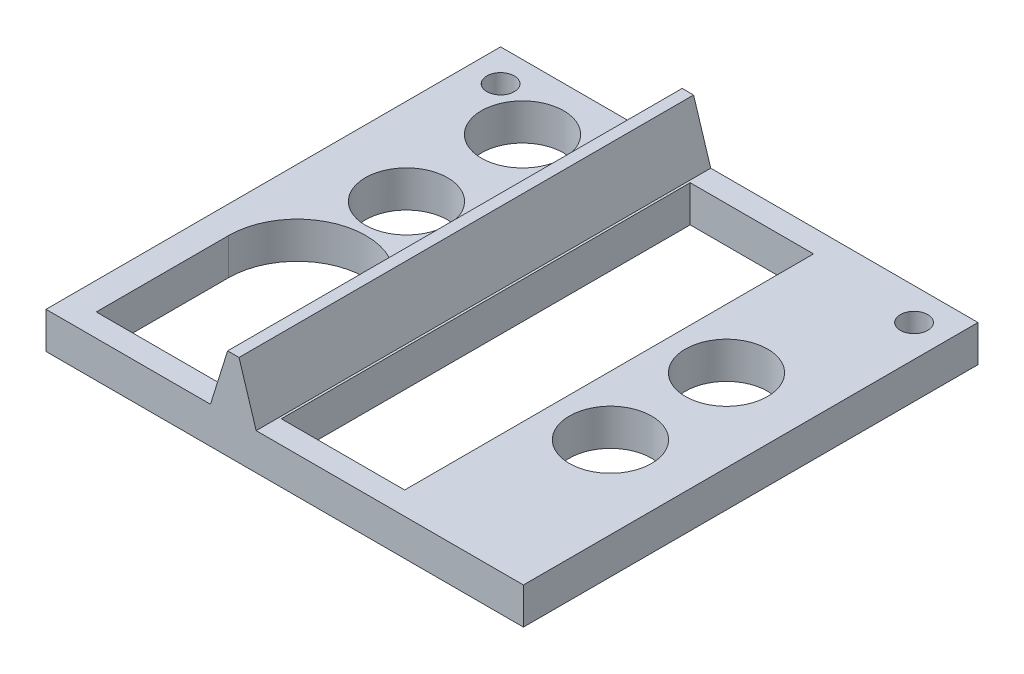
from build123d import *

# Parameters (mm, degrees)
SKETCH1_W           = 104.5
SKETCH1_H           = 99.5
BOSS_EXTRUDE1_DEPTH = 8
CUT_EXTRUDE1_REACH  = 10
SKETCH2_R           = 9
SKETCH2_R_2         = 15
BOSS_EXTRUDE2_DEPTH = 99.5
CUT_EXTRUDE2_REACH  = 10
SKETCH4_W           = 27
SKETCH4_H           = 89.5
CUT_EXTRUDE3_REACH  = 10
SKETCH5_W           = 30
SKETCH5_H           = 28.99
CUT_EXTRUDE4_REACH  = 10
SKETCH6_R           = 3


with BuildPart() as part:
    # Sketch1 → Boss-Extrude1 (new body)
    with BuildSketch(Plane(origin=(0, 0, 0), x_dir=(1, 0, 0), z_dir=(0, 1, 0))):
        Rectangle(SKETCH1_W, SKETCH1_H)
    extrude(amount=BOSS_EXTRUDE1_DEPTH)

    # Sketch2 → Cut-Extrude1 (cut, up to next)
    with BuildSketch(Plane.XZ, mode=Mode.PRIVATE) as cut_extrude1_sk1:
        with Locations((-33.25, -10.15)):
            Circle(SKETCH2_R)
    cut_extrude1_tool1 = extrude(cut_extrude1_sk1.sketch, amount=-CUT_EXTRUDE1_REACH, mode=Mode.PRIVATE) & part.part
    add(cut_extrude1_tool1.solids().sort_by_distance((-33.25, 0, -10.15))[0], mode=Mode.SUBTRACT)
    # Sketch2 → Cut-Extrude1 (cut, up to next)
    with BuildSketch(Plane.XZ, mode=Mode.PRIVATE) as cut_extrude1_sk2:
        with Locations((-33.25, -35.55)):
            Circle(SKETCH2_R)
    cut_extrude1_tool2 = extrude(cut_extrude1_sk2.sketch, amount=-CUT_EXTRUDE1_REACH, mode=Mode.PRIVATE) & part.part
    add(cut_extrude1_tool2.solids().sort_by_distance((-33.25, 0, -35.55))[0], mode=Mode.SUBTRACT)
    # Sketch2 → Cut-Extrude1 (cut, up to next)
    with BuildSketch(Plane.XZ, mode=Mode.PRIVATE) as cut_extrude1_sk3:
        with Locations((34.25, 12.7)):
            Circle(SKETCH2_R)
    cut_extrude1_tool3 = extrude(cut_extrude1_sk3.sketch, amount=-CUT_EXTRUDE1_REACH, mode=Mode.PRIVATE) & part.part
    add(cut_extrude1_tool3.solids().sort_by_distance((34.25, 0, 12.7))[0], mode=Mode.SUBTRACT)
    # Sketch2 → Cut-Extrude1 (cut, up to next)
    with BuildSketch(Plane.XZ, mode=Mode.PRIVATE) as cut_extrude1_sk4:
        with Locations((34.25, -12.7)):
            Circle(SKETCH2_R)
    cut_extrude1_tool4 = extrude(cut_extrude1_sk4.sketch, amount=-CUT_EXTRUDE1_REACH, mode=Mode.PRIVATE) & part.part
    add(cut_extrude1_tool4.solids().sort_by_distance((34.25, 0, -12.7))[0], mode=Mode.SUBTRACT)
    # Sketch2 → Cut-Extrude1 (cut, up to next)
    with BuildSketch(Plane.XZ, mode=Mode.PRIVATE) as cut_extrude1_sk5:
        with Locations((-31.25, 15.76)):
            Circle(SKETCH2_R_2)
    cut_extrude1_tool5 = extrude(cut_extrude1_sk5.sketch, amount=-CUT_EXTRUDE1_REACH, mode=Mode.PRIVATE) & part.part
    add(cut_extrude1_tool5.solids().sort_by_distance((-31.25, 0, 15.76))[0], mode=Mode.SUBTRACT)

    # Sketch3 → Boss-Extrude2 (add)
    with BuildSketch(Plane(origin=(0, 0, -49.75), x_dir=(-1, 0, 0), z_dir=(0, 0, -1))):
        Polygon((6.25, 8), (10, 20), (12.5, 20), (16.25, 8), align=None)
    extrude(amount=-BOSS_EXTRUDE2_DEPTH)

    # Sketch4 → Cut-Extrude2 (cut, up to next)
    with BuildSketch(Plane(origin=(0, 8, 0), x_dir=(1, 0, 0), z_dir=(0, 1, 0)), mode=Mode.PRIVATE) as cut_extrude2_sk1:
        with Locations((7.75, 0)):
            Rectangle(SKETCH4_W, SKETCH4_H)
    cut_extrude2_tool1 = extrude(cut_extrude2_sk1.sketch, amount=-CUT_EXTRUDE2_REACH, mode=Mode.PRIVATE) & part.part
    add(cut_extrude2_tool1.solids().sort_by_distance((7.75, 8, 0))[0], mode=Mode.SUBTRACT)

    # Sketch5 → Cut-Extrude3 (cut, up to next)
    with BuildSketch(Plane(origin=(0, 8, 0), x_dir=(1, 0, 0), z_dir=(0, 1, 0)), mode=Mode.PRIVATE) as cut_extrude3_sk1:
        with Locations((-31.25, -30.255)):
            Rectangle(SKETCH5_W, SKETCH5_H)
    cut_extrude3_tool1 = extrude(cut_extrude3_sk1.sketch, amount=-CUT_EXTRUDE3_REACH, mode=Mode.PRIVATE) & part.part
    add(cut_extrude3_tool1.solids().sort_by_distance((-31.25, 8, 30.255))[0], mode=Mode.SUBTRACT)

    # Sketch6 → Cut-Extrude4 (cut, up to next)
    with BuildSketch(Plane(origin=(0, 8, 0), x_dir=(1, 0, 0), z_dir=(0, 1, 0)), mode=Mode.PRIVATE) as cut_extrude4_sk1:
        with Locations((-45.25, 42.75)):
            Circle(SKETCH6_R)
    cut_extrude4_tool1 = extrude(cut_extrude4_sk1.sketch, amount=-CUT_EXTRUDE4_REACH, mode=Mode.PRIVATE) & part.part
    add(cut_extrude4_tool1.solids().sort_by_distance((-45.25, 8, -42.75))[0], mode=Mode.SUBTRACT)
    # Sketch6 → Cut-Extrude4 (cut, up to next)
    with BuildSketch(Plane(origin=(0, 8, 0), x_dir=(1, 0, 0), z_dir=(0, 1, 0)), mode=Mode.PRIVATE) as cut_extrude4_sk2:
        with Locations((45.25, 42.75)):
            Circle(SKETCH6_R)
    cut_extrude4_tool2 = extrude(cut_extrude4_sk2.sketch, amount=-CUT_EXTRUDE4_REACH, mode=Mode.PRIVATE) & part.part
    add(cut_extrude4_tool2.solids().sort_by_distance((45.25, 8, -42.75))[0], mode=Mode.SUBTRACT)


solid = part.part
